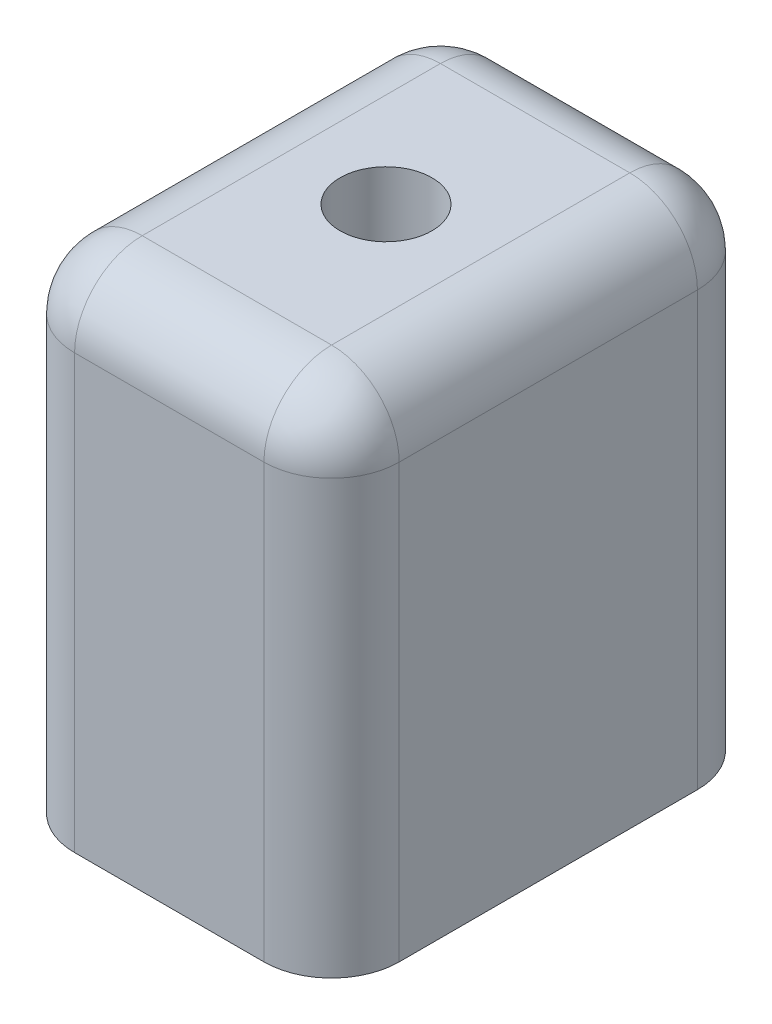
from build123d import *

# Parameters (mm, degrees)
SKETCH1_W           = 24
SKETCH1_H           = 32.05
SKETCH1_R           = 2.15
BOSS_EXTRUDE1_DEPTH = 37
SKETCH2_R           = 2.15
BOSS_EXTRUDE2_DEPTH = 30
SKETCH3_R           = 3.4
CUT_EXTRUDE1_DEPTH  = 12
FILLET1_R           = 5
SKETCH4_R           = 2.75
BOSS_EXTRUDE3_DEPTH = 5
FILLET2_R           = 1.5


with BuildPart() as part:
    # Sketch1 → Boss-Extrude1 (new body)
    with BuildSketch(Plane(origin=(0, 0, 0), x_dir=(1, 0, 0), z_dir=(0, 1, 0))):
        with Locations((10.056177559, 9.020502124)):
            Rectangle(SKETCH1_W, SKETCH1_H)
        with Locations((5.056177559, 9.020502124)):
            Circle(SKETCH1_R, mode=Mode.SUBTRACT)
        with Locations((15.056177559, 9.020502124)):
            Circle(SKETCH1_R, mode=Mode.SUBTRACT)
        with Locations((10.056177559, 19.895502124)):
            Circle(SKETCH1_R, mode=Mode.SUBTRACT)
        with Locations((10.056177559, -1.854497876)):
            Circle(SKETCH1_R, mode=Mode.SUBTRACT)
    extrude(amount=BOSS_EXTRUDE1_DEPTH)

    # Sketch2 → Boss-Extrude2 (add)
    with BuildSketch(Plane(origin=(0, 37, 0), x_dir=(1, 0, 0), z_dir=(0, 1, 0))):
        with Locations((10.056177559, 19.895502124)):
            Circle(SKETCH2_R)
        with Locations((15.056177559, 9.020502124)):
            Circle(SKETCH2_R)
        with Locations((10.056177559, -1.854497876)):
            Circle(SKETCH2_R)
        with Locations((5.056177559, 9.020502124)):
            Circle(SKETCH2_R)
    extrude(amount=-BOSS_EXTRUDE2_DEPTH)

    # Sketch3 → Cut-Extrude1 (cut)
    with BuildSketch(Plane(origin=(0, 37, 0), x_dir=(1, 0, 0), z_dir=(0, 1, 0))):
        with Locations((10.056177559, 9.020502124)):
            Circle(SKETCH3_R)
    extrude(amount=-CUT_EXTRUDE1_DEPTH, mode=Mode.SUBTRACT)

    # Fillet1
    fillet1_edges = [part.edges().sort_by_distance(p)[0] for p in [
        (22.056177559, 37, -9.020502124),
        (10.056177559, 37, -25.045502124),
        (-1.943822441, 37, -9.020502124),
        (-1.943822441, 18.5, -25.045502124),
        (22.056177559, 18.5, -25.045502124),
        (22.056177559, 18.5, 7.004497876),
        (-1.943822441, 18.5, 7.004497876),
        (10.056177559, 37, 7.004497876),
    ]]
    fillet(fillet1_edges, radius=FILLET1_R)

    # Sketch4 → Boss-Extrude3 (add)
    with BuildSketch(Plane.ZY.offset(1.943822441)):
        with Locations((-9.020502124, 4)):
            Circle(SKETCH4_R)
    extrude(amount=BOSS_EXTRUDE3_DEPTH)

    # Fillet2
    fillet2_edges = [part.edges().sort_by_distance(p)[0] for p in [
        (-6.943822441, 4, -11.770502124),
    ]]
    fillet(fillet2_edges, radius=FILLET2_R)


solid = part.part
